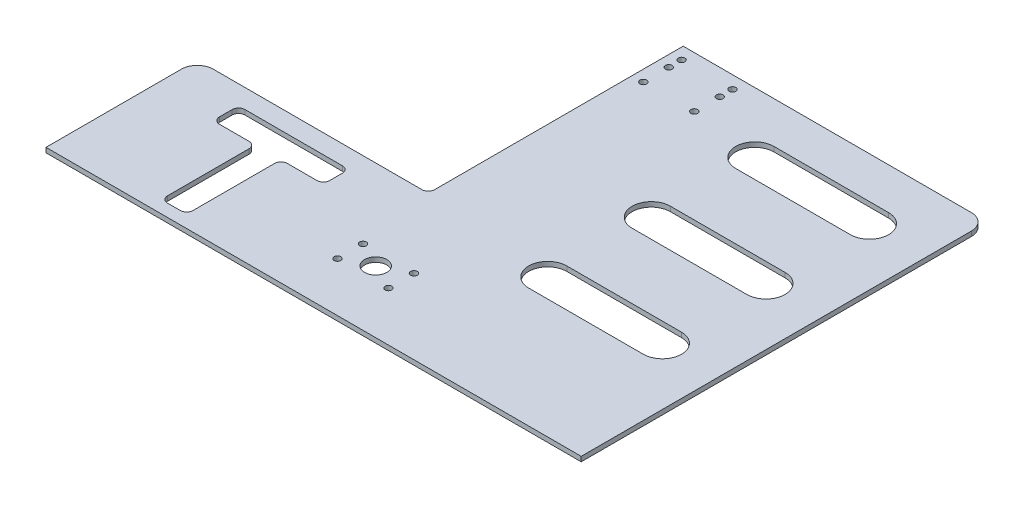
from build123d import *

# Parameters (mm, degrees)
SKETCH1_R               = 7
SKETCH1_R_2             = 2.1
BOSS_EXTRUDE1_DEPTH     = 3
SKETCH2_W               = 336
SKETCH2_H               = 4
CUT_EXTRUDE1_DEPTH      = 1
CUT_EXTRUDE1_DEPTH_BACK = 4


with BuildPart() as part:
    # Sketch1 → Boss-Extrude1 (new body)
    with BuildSketch(Plane(origin=(0, 0, 0), x_dir=(1, 0, 0), z_dir=(0, 1, 0))):
        with BuildLine():
            Line((-23, 216), (158, 216))
            ThreePointArc((158, 216), (165.071067812, 213.071067812), (168, 206))
            Line((168, 206), (168, -43))
            Line((168, -43), (-168, -43))
            Line((-168, -43), (-168, 46))
            ThreePointArc((-168, 46), (-165.071067812, 53.071067812), (-158, 56))
            Line((-158, 56), (-27, 56))
            ThreePointArc((-27, 56), (-24.171572875, 57.171572875), (-23, 60))
            Line((-23, 60), (-23, 216))
        make_face()
        Circle(SKETCH1_R, mode=Mode.SUBTRACT)
        with Locations((16, 8)):
            Circle(SKETCH1_R_2, mode=Mode.SUBTRACT)
        with Locations((16, -8)):
            Circle(SKETCH1_R_2, mode=Mode.SUBTRACT)
        with Locations((16, 208)):
            Circle(SKETCH1_R_2, mode=Mode.SUBTRACT)
        with Locations((16, 184)):
            Circle(SKETCH1_R_2, mode=Mode.SUBTRACT)
        with Locations((16, 200)):
            Circle(SKETCH1_R_2, mode=Mode.SUBTRACT)
        with Locations((-16, 184)):
            Circle(SKETCH1_R_2, mode=Mode.SUBTRACT)
        with Locations((-16, 200)):
            Circle(SKETCH1_R_2, mode=Mode.SUBTRACT)
        with Locations((-16, 208)):
            Circle(SKETCH1_R_2, mode=Mode.SUBTRACT)
        with Locations((-16, -8)):
            Circle(SKETCH1_R_2, mode=Mode.SUBTRACT)
        with Locations((-16, 8)):
            Circle(SKETCH1_R_2, mode=Mode.SUBTRACT)
        with BuildLine():
            Line((-103.5, -27.189984024), (-103.5, 24))
            ThreePointArc((-103.5, 24), (-104.671572875, 26.828427125), (-107.5, 28))
            Line((-107.5, 28), (-126.109686491, 28))
            ThreePointArc((-126.109686491, 28), (-128.938113615, 29.171572875), (-130.109686491, 32))
            Line((-130.109686491, 32), (-130.109686491, 40))
            ThreePointArc((-130.109686491, 40), (-128.938113615, 42.828427125), (-126.109686491, 44))
            Line((-126.109686491, 44), (-64.890313509, 44))
            ThreePointArc((-64.890313509, 44), (-62.061886385, 42.828427125), (-60.890313509, 40))
            Line((-60.890313509, 40), (-60.890313509, 32))
            ThreePointArc((-60.890313509, 32), (-62.061886385, 29.171572875), (-64.890313509, 28))
            Line((-64.890313509, 28), (-83.5, 28))
            ThreePointArc((-83.5, 28), (-86.328427125, 26.828427125), (-87.5, 24))
            Line((-87.5, 24), (-87.5, -27.189984024))
            ThreePointArc((-87.5, -27.189984024), (-88.671572875, -30.018411149), (-91.5, -31.189984024))
            Line((-91.5, -31.189984024), (-99.5, -31.189984024))
            ThreePointArc((-99.5, -31.189984024), (-102.328427125, -30.018411149), (-103.5, -27.189984024))
        make_face(mode=Mode.SUBTRACT)
        with BuildLine():
            Line((60, 60), (132, 60))
            ThreePointArc((132, 60), (144, 48), (132, 36))
            Line((132, 36), (60, 36))
            ThreePointArc((60, 36), (48, 48), (60, 60))
        make_face(mode=Mode.SUBTRACT)
        with BuildLine():
            Line((60, 125), (132, 125))
            ThreePointArc((132, 125), (144, 113), (132, 101))
            Line((132, 101), (60, 101))
            ThreePointArc((60, 101), (48, 113), (60, 125))
        make_face(mode=Mode.SUBTRACT)
        with BuildLine():
            Line((60, 190), (132, 190))
            ThreePointArc((132, 190), (144, 178), (132, 166))
            Line((132, 166), (60, 166))
            ThreePointArc((60, 166), (48, 178), (60, 190))
        make_face(mode=Mode.SUBTRACT)
    extrude(amount=BOSS_EXTRUDE1_DEPTH)

    # Sketch2 → Cut-Extrude1 (cut, two sides)
    with BuildSketch(Plane(origin=(0, 3, 0), x_dir=(1, 0, 0), z_dir=(0, 1, 0))) as cut_extrude1_sk:
        with Locations((0, -41)):
            Rectangle(SKETCH2_W, SKETCH2_H)
    extrude(amount=CUT_EXTRUDE1_DEPTH, mode=Mode.SUBTRACT)
    extrude(cut_extrude1_sk.sketch, amount=-CUT_EXTRUDE1_DEPTH_BACK, mode=Mode.SUBTRACT)


solid = part.part
